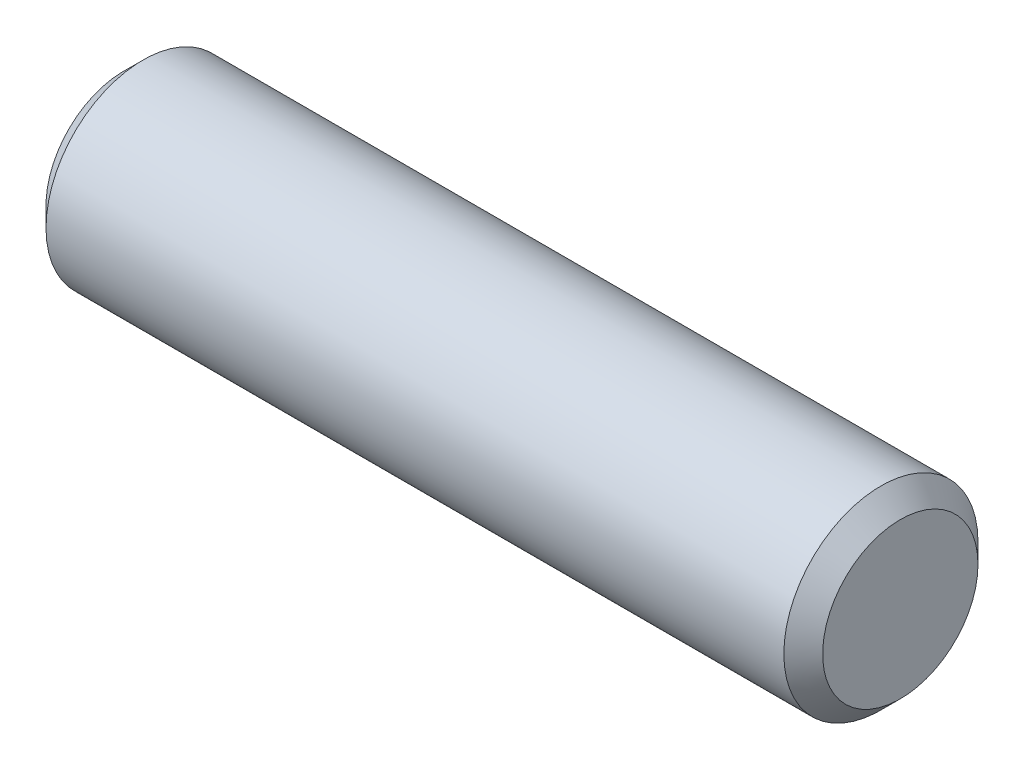
from build123d import *

# Parameters (mm, degrees)
SKETCH2_R           = 1.5875
EXTRUDE1_DEPTH      = 6.35
EXTRUDE1_DEPTH_BACK = 6.35
CHAMFER1_SIZE       = 0.3175


with BuildPart() as part:
    # Sketch2 → Extrude1 (new body, two sides)
    with BuildSketch(Plane(origin=(0, 0, 0), x_dir=(0, 0, -1), z_dir=(1, 0, 0))) as extrude1_sk:
        Circle(SKETCH2_R)
    extrude(amount=EXTRUDE1_DEPTH)
    extrude(extrude1_sk.sketch, amount=-EXTRUDE1_DEPTH_BACK)

    # Chamfer1
    chamfer1_edges = [part.edges().sort_by_distance(p)[0] for p in [
        (-6.35, 0, 1.5875),
        (6.35, 0, 1.5875),
    ]]
    chamfer(chamfer1_edges, length=CHAMFER1_SIZE)


solid = part.part
